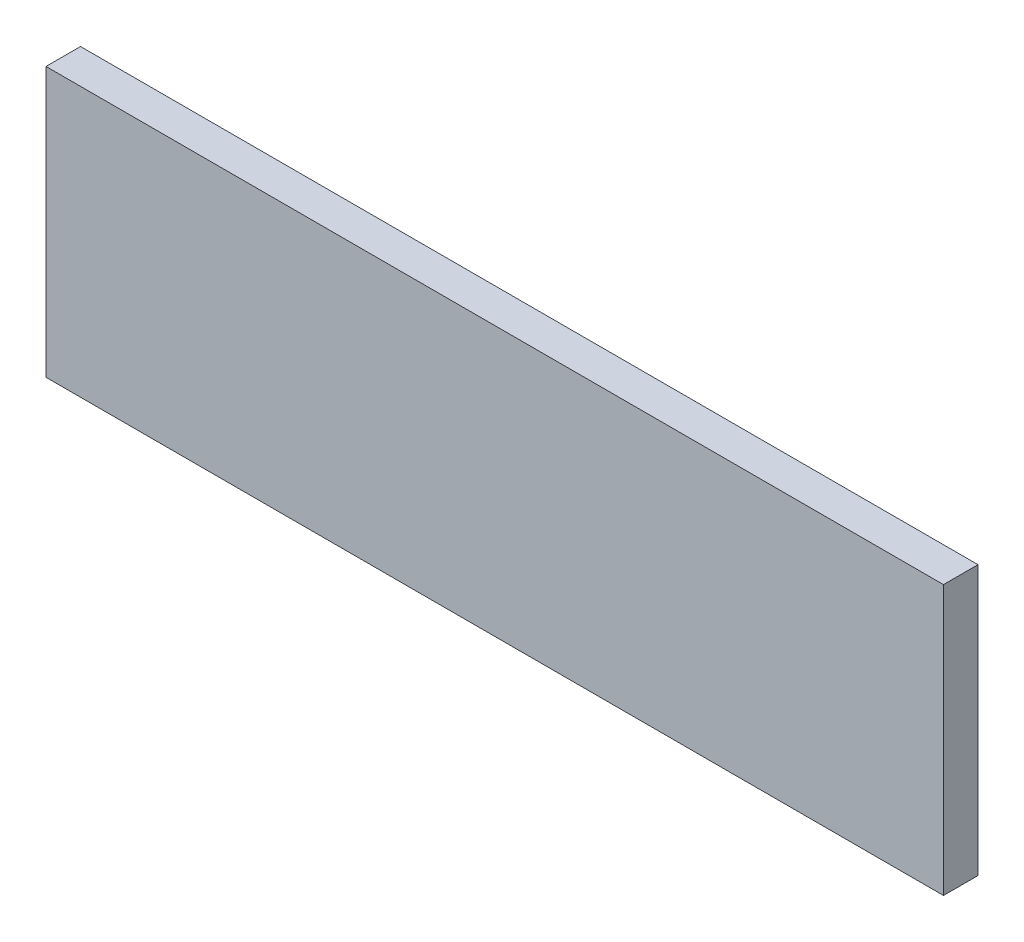
from build123d import *

# Parameters (mm, degrees)
SKETCH1_W           = 33.02
SKETCH1_H           = 9.906
BOSS_EXTRUDE1_DEPTH = 1.27


with BuildPart() as part:
    # Sketch1 → Boss-Extrude1 (new body)
    with BuildSketch(Plane.XY):
        with Locations((16.51, 4.953)):
            Rectangle(SKETCH1_W, SKETCH1_H)
    extrude(amount=BOSS_EXTRUDE1_DEPTH)


solid = part.part
